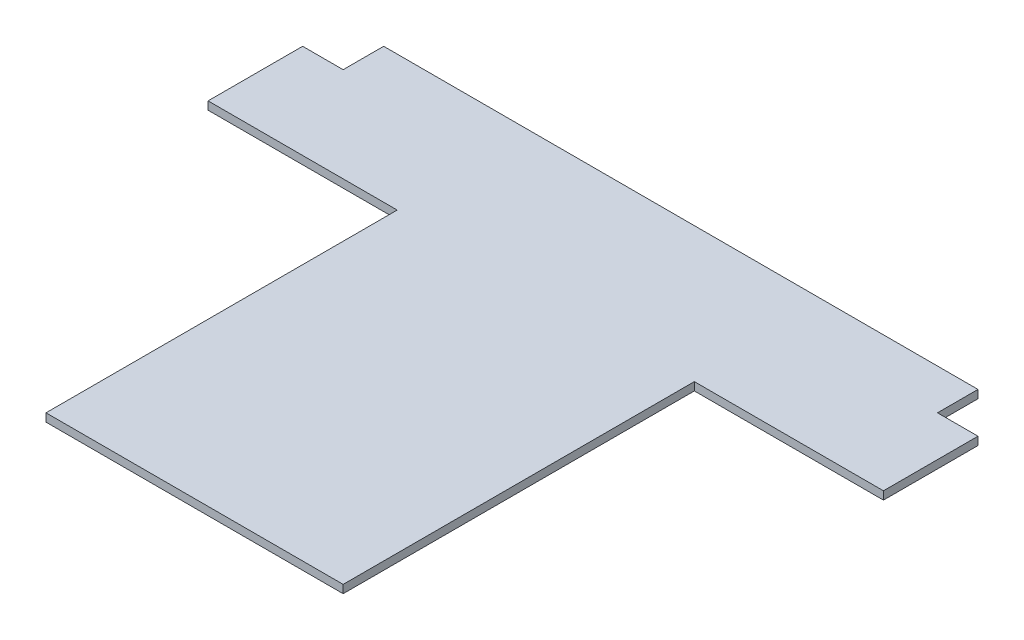
from build123d import *

# Parameters (mm, degrees)
RESSALTO_EXTRUS_O1_DEPTH = 6


with BuildPart() as part:
    # Esboço1 → Ressalto-extrusão1 (new body)
    with BuildSketch(Plane(origin=(0, 0, 0), x_dir=(1, 0, 0), z_dir=(0, 1, 0))):
        Polygon((-250, 80), (-250, 150), (-220, 150), (-220, 180), (220, 180), (220, 150), (250, 150), (250, 80), (110, 80), (110, -180), (-110, -180), (-110, 80), align=None)
    extrude(amount=RESSALTO_EXTRUS_O1_DEPTH)


solid = part.part
